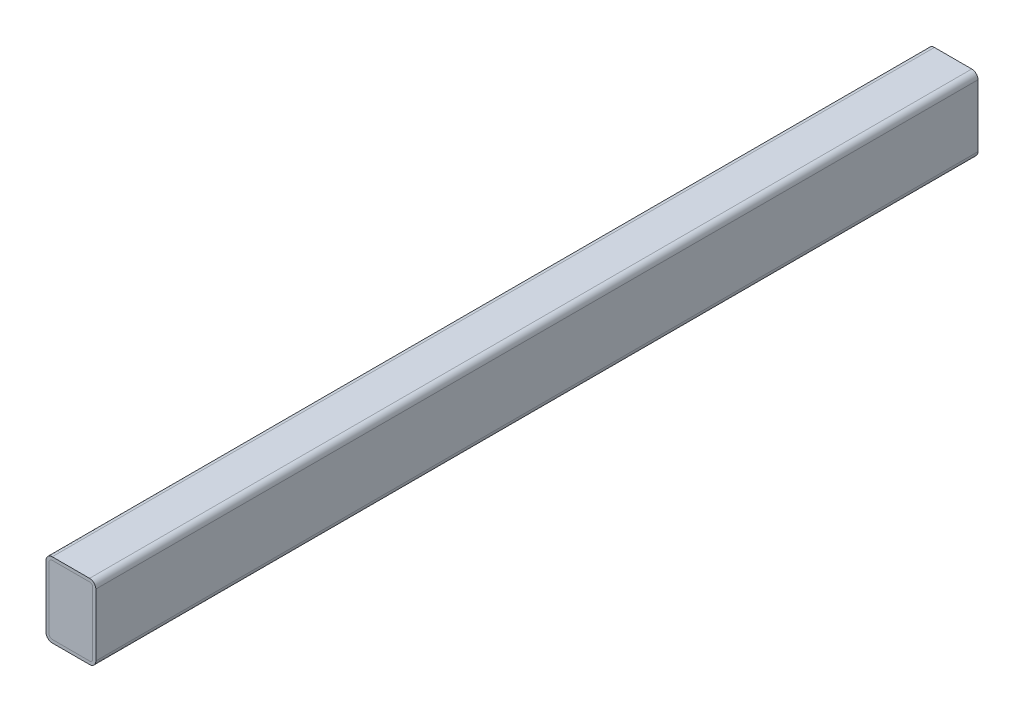
from build123d import *

# Parameters (mm, degrees)
BOSS_EXTRUDE2_DEPTH = 449.961
BOSS_EXTRUDE3_DEPTH = 899.922


with BuildPart() as part:
    # Sketch13 → Boss-Extrude2 (new body, symmetric)
    with BuildSketch(Plane.XY):
        with BuildLine():
            Line((19.05, -38.1), (-19.05, -38.1))
            ThreePointArc((-19.05, -38.1), (-23.540128061, -36.240128061), (-25.4, -31.75))
            Line((-25.4, -31.75), (-25.4, 31.75))
            ThreePointArc((-25.4, 31.75), (-23.540128061, 36.240128061), (-19.05, 38.1))
            Line((-19.05, 38.1), (19.05, 38.1))
            ThreePointArc((19.05, 38.1), (23.540128061, 36.240128061), (25.4, 31.75))
            Line((25.4, 31.75), (25.4, -31.75))
            ThreePointArc((25.4, -31.75), (23.540128061, -36.240128061), (19.05, -38.1))
        make_face()
        with BuildLine():
            Line((19.05, -34.925), (-19.05, -34.925))
            ThreePointArc((-19.05, -34.925), (-21.29506403, -33.99506403), (-22.225, -31.75))
            Line((-22.225, -31.75), (-22.225, 31.75))
            ThreePointArc((-22.225, 31.75), (-21.29506403, 33.99506403), (-19.05, 34.925))
            Line((-19.05, 34.925), (19.05, 34.925))
            ThreePointArc((19.05, 34.925), (21.29506403, 33.99506403), (22.225, 31.75))
            Line((22.225, 31.75), (22.225, -31.75))
            ThreePointArc((22.225, -31.75), (21.29506403, -33.99506403), (19.05, -34.925))
        make_face(mode=Mode.SUBTRACT)
    extrude(amount=BOSS_EXTRUDE2_DEPTH, both=True)


with BuildPart() as body_2:
    # Sketch14 → Boss-Extrude3 (new body)
    with BuildSketch(Plane.XY.offset(449.961)):
        with BuildLine():
            Line((-19.05, -34.925), (19.05, -34.925))
            ThreePointArc((19.05, -34.925), (21.29506403, -33.99506403), (22.225, -31.75))
            Line((22.225, -31.75), (22.225, 31.75))
            ThreePointArc((22.225, 31.75), (21.29506403, 33.99506403), (19.05, 34.925))
            Line((19.05, 34.925), (-19.05, 34.925))
            ThreePointArc((-19.05, 34.925), (-21.29506403, 33.99506403), (-22.225, 31.75))
            Line((-22.225, 31.75), (-22.225, -31.75))
            ThreePointArc((-22.225, -31.75), (-21.29506403, -33.99506403), (-19.05, -34.925))
        make_face()
    extrude(amount=-BOSS_EXTRUDE3_DEPTH)


solid = Compound([part.part, body_2.part])
